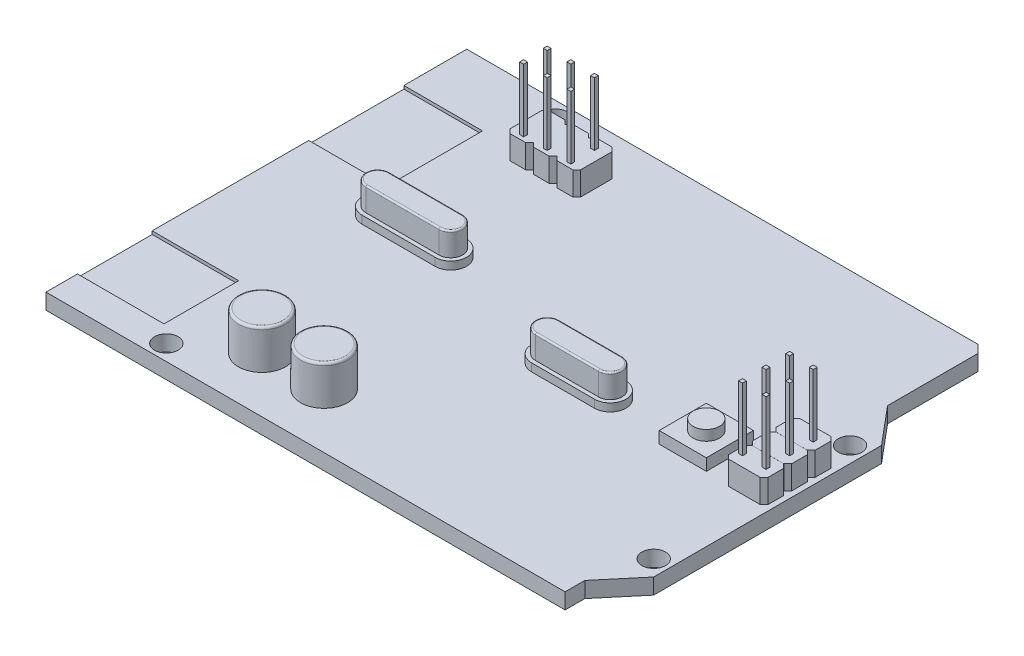
from build123d import *

# Parameters (mm, degrees)
BOSS_EXTRUDE1_DEPTH  = 2
SKETCH2_R            = 1.5
CUT_EXTRUDE1_DEPTH   = 3
SKETCH3_W            = 11
SKETCH3_H            = 9.5
SKETCH3_W_2          = 10
SKETCH3_H_2          = 12.1
CUT_EXTRUDE3_DEPTH   = 0.4
BOSS_EXTRUDE4_DEPTH  = 3
LPATTERN2_COUNT      = 3
LPATTERN2_PITCH      = 3
SKETCH7_W            = 0.5
SKETCH7_H            = 0.5
BOSS_EXTRUDE6_DEPTH  = 8
LPATTERN3_COUNT      = 3
LPATTERN3_PITCH      = 3
LPATTERN3_COUNT_DIR2 = 2
LPATTERN3_PITCH_DIR2 = 3
BOSS_EXTRUDE8_DEPTH  = 3
LPATTERN4_COUNT      = 3
LPATTERN4_PITCH      = 3
SKETCH10_W           = 0.5
SKETCH10_H           = 0.5
BOSS_EXTRUDE9_DEPTH  = 8
LPATTERN6_COUNT      = 3
LPATTERN6_PITCH      = 3
LPATTERN6_COUNT_DIR2 = 2
LPATTERN6_PITCH_DIR2 = 3
SKETCH11_W           = 6
SKETCH11_H           = 6
BOSS_EXTRUDE10_DEPTH = 1.5
SKETCH12_R           = 1.680467601
BOSS_EXTRUDE11_DEPTH = 1.3
BOSS_EXTRUDE13_DEPTH = 1
BOSS_EXTRUDE14_DEPTH = 3
FILLET1_R            = 0.2
BOSS_EXTRUDE15_DEPTH = 1
BOSS_EXTRUDE16_DEPTH = 3
FILLET2_R            = 0.2
SKETCH29_R           = 3
BOSS_EXTRUDE17_DEPTH = 5
FILLET3_R            = 0.3


with BuildPart() as part:
    # Sketch1 → Boss-Extrude1 (new body)
    with BuildSketch(Plane(origin=(0, 0, 0), x_dir=(1, 0, 0), z_dir=(0, 1, 0))):
        Polygon((0, 0), (0, 53.5), (65, 53.5), (66, 52.5), (66, 41), (70, 36.23298563), (70, 7.26701437), (66, 2.5), (66, 0), align=None)
    extrude(amount=BOSS_EXTRUDE1_DEPTH)

    # Sketch2 → Cut-Extrude1 (cut, through all)
    with BuildSketch(Plane(origin=(0, 2, 0), x_dir=(1, 0, 0), z_dir=(0, 1, 0))):
        with Locations((68, 34.23298563)):
            Circle(SKETCH2_R)
        with Locations((68, 9.26701437)):
            Circle(SKETCH2_R)
        with Locations((13.3, 2)):
            Circle(SKETCH2_R)
        with Locations((13.3, 51.5)):
            Circle(SKETCH2_R)
    extrude(amount=-CUT_EXTRUDE1_DEPTH, mode=Mode.SUBTRACT)

    # Sketch3 → Cut-Extrude3 (cut)
    with BuildSketch(Plane(origin=(0, 2, 0), x_dir=(1, 0, 0), z_dir=(0, 1, 0))):
        with Locations((5.5, 8.75)):
            Rectangle(SKETCH3_W, SKETCH3_H)
        with Locations((5, 39.45)):
            Rectangle(SKETCH3_W_2, SKETCH3_H_2)
    extrude(amount=-CUT_EXTRUDE3_DEPTH, mode=Mode.SUBTRACT)

    # Sketch6 → Boss-Extrude4 (add)
    with BuildSketch(Plane(origin=(0, 2, 0), x_dir=(1, 0, 0), z_dir=(0, 1, 0))):
        Polygon((64.8, 31), (68.8, 31), (69.3, 30.5), (69.3, 28.504777208), (68.8, 28.004777208), (64.8, 28.004777208), (64.3, 28.504777208), (64.3, 30.5), align=None)
    boss_extrude4 = extrude(amount=BOSS_EXTRUDE4_DEPTH)

    # LPattern2: Boss-Extrude4 ×3
    with Locations(*[(0, 0, i * LPATTERN2_PITCH) for i in range(1, LPATTERN2_COUNT)]):
        add(boss_extrude4)

    # Sketch7 → Boss-Extrude6 (add)
    with BuildSketch(Plane(origin=(0, 5, 0), x_dir=(1, 0, 0), z_dir=(0, 1, 0))):
        with Locations((65.05, 29.5)):
            Rectangle(SKETCH7_W, SKETCH7_H)
    boss_extrude6 = extrude(amount=BOSS_EXTRUDE6_DEPTH)

    # LPattern3: Boss-Extrude6 3 × 2
    with Locations(*[(j * LPATTERN3_PITCH_DIR2, 0, i * LPATTERN3_PITCH) for i in range(LPATTERN3_COUNT) for j in range(LPATTERN3_COUNT_DIR2) if (i, j) != (0, 0)]):
        add(boss_extrude6)

    # Sketch9 → Boss-Extrude8 (add)
    with BuildSketch(Plane(origin=(0, 2, 0), x_dir=(1, 0, 0), z_dir=(0, 1, 0))):
        Polygon((14.518797874, 48.458802695), (15.018797874, 48.958802695), (17.018797874, 48.958802695), (17.518797874, 48.458802695), (17.518797874, 44.458802695), (17.018797874, 43.958802695), (15.018797874, 43.958802695), (14.518797874, 44.458802695), align=None)
    boss_extrude8 = extrude(amount=BOSS_EXTRUDE8_DEPTH)

    # LPattern4: Boss-Extrude8 ×3
    with Locations(*[(i * LPATTERN4_PITCH, 0, 0) for i in range(1, LPATTERN4_COUNT)]):
        add(boss_extrude8)

    # Sketch10 → Boss-Extrude9 (add)
    with BuildSketch(Plane(origin=(0, 5, 0), x_dir=(1, 0, 0), z_dir=(0, 1, 0))):
        with Locations((16.018797874, 44.708802695)):
            Rectangle(SKETCH10_W, SKETCH10_H)
    boss_extrude9 = extrude(amount=BOSS_EXTRUDE9_DEPTH)

    # LPattern6: Boss-Extrude9 3 × 2
    with Locations(*[(i * LPATTERN6_PITCH, 0, -j * LPATTERN6_PITCH_DIR2) for i in range(LPATTERN6_COUNT) for j in range(LPATTERN6_COUNT_DIR2) if (i, j) != (0, 0)]):
        add(boss_extrude9)

    # Sketch11 → Boss-Extrude10 (add)
    with BuildSketch(Plane(origin=(0, 2, 0), x_dir=(1, 0, 0), z_dir=(0, 1, 0))):
        with Locations((58.717415981, 25.240731318)):
            Rectangle(SKETCH11_W, SKETCH11_H)
    extrude(amount=BOSS_EXTRUDE10_DEPTH)

    # Sketch12 → Boss-Extrude11 (add)
    with BuildSketch(Plane(origin=(0, 3.5, 0), x_dir=(1, 0, 0), z_dir=(0, 1, 0))):
        with Locations((58.717415981, 25.240731318)):
            Circle(SKETCH12_R)
    extrude(amount=BOSS_EXTRUDE11_DEPTH)

    # Sketch15 → Boss-Extrude13 (add)
    with BuildSketch(Plane(origin=(0, 2, 0), x_dir=(1, 0, 0), z_dir=(0, 1, 0))):
        with BuildLine():
            Line((39.657997107, 26.083421199), (47.657997107, 26.083421199))
            ThreePointArc((47.657997107, 26.083421199), (49.657997107, 24.083421199), (47.657997107, 22.083421199))
            Line((47.657997107, 22.083421199), (39.657997107, 22.083421199))
            ThreePointArc((39.657997107, 22.083421199), (37.657997107, 24.083421199), (39.657997107, 26.083421199))
        make_face()
    extrude(amount=BOSS_EXTRUDE13_DEPTH)

    # Sketch26 → Boss-Extrude14 (add)
    with BuildSketch(Plane(origin=(0, 3, 0), x_dir=(1, 0, 0), z_dir=(0, 1, 0))):
        with BuildLine():
            Line((39.657997107, 25.583421199), (47.657997107, 25.583421199))
            ThreePointArc((47.657997107, 25.583421199), (49.157997107, 24.083421199), (47.657997107, 22.583421199))
            Line((47.657997107, 22.583421199), (39.657997107, 22.583421199))
            ThreePointArc((39.657997107, 22.583421199), (38.157997107, 24.083421199), (39.657997107, 25.583421199))
        make_face()
    extrude(amount=BOSS_EXTRUDE14_DEPTH)

    # Fillet1
    fillet1_edges = [part.edges().sort_by_distance(p)[0] for p in [
        (38.157997107, 6, -24.083421199),
        (43.657997107, 6, -22.583421199),
        (49.157997107, 6, -24.083421199),
        (43.657997107, 6, -25.583421199),
    ]]
    fillet(fillet1_edges, radius=FILLET1_R)

    # Sketch27 → Boss-Extrude15 (add)
    with BuildSketch(Plane(origin=(0, 2, 0), x_dir=(1, 0, 0), z_dir=(0, 1, 0))):
        with BuildLine():
            Line((12.60771505, 31.568908556), (21.900403763, 31.568908556))
            ThreePointArc((21.900403763, 31.568908556), (23.900403763, 29.568908556), (21.900403763, 27.568908556))
            Line((21.900403763, 27.568908556), (12.60771505, 27.568908556))
            ThreePointArc((12.60771505, 27.568908556), (10.60771505, 29.568908556), (12.60771505, 31.568908556))
        make_face()
    extrude(amount=BOSS_EXTRUDE15_DEPTH)

    # Sketch28 → Boss-Extrude16 (add)
    with BuildSketch(Plane(origin=(0, 3, 0), x_dir=(1, 0, 0), z_dir=(0, 1, 0))):
        with BuildLine():
            Line((12.60771505, 31.068908556), (21.900403763, 31.068908556))
            ThreePointArc((21.900403763, 31.068908556), (23.400403763, 29.568908556), (21.900403763, 28.068908556))
            Line((21.900403763, 28.068908556), (12.60771505, 28.068908556))
            ThreePointArc((12.60771505, 28.068908556), (11.10771505, 29.568908556), (12.60771505, 31.068908556))
        make_face()
    extrude(amount=BOSS_EXTRUDE16_DEPTH)

    # Fillet2
    fillet2_edges = [part.edges().sort_by_distance(p)[0] for p in [
        (11.10771505, 6, -29.568908556),
        (17.254059406, 6, -28.068908556),
        (23.400403763, 6, -29.568908556),
        (17.254059406, 6, -31.068908556),
    ]]
    fillet(fillet2_edges, radius=FILLET2_R)

    # Sketch29 → Boss-Extrude17 (add)
    with BuildSketch(Plane(origin=(0, 2, 0), x_dir=(1, 0, 0), z_dir=(0, 1, 0))):
        with Locations((20.457491656, 7)):
            Circle(SKETCH29_R)
        with Locations((28.357680745, 7)):
            Circle(SKETCH29_R)
    extrude(amount=BOSS_EXTRUDE17_DEPTH)

    # Fillet3
    fillet3_edges = [part.edges().sort_by_distance(p)[0] for p in [
        (17.457491656, 7, -7),
        (25.357680745, 7, -7),
    ]]
    fillet(fillet3_edges, radius=FILLET3_R)


solid = part.part
